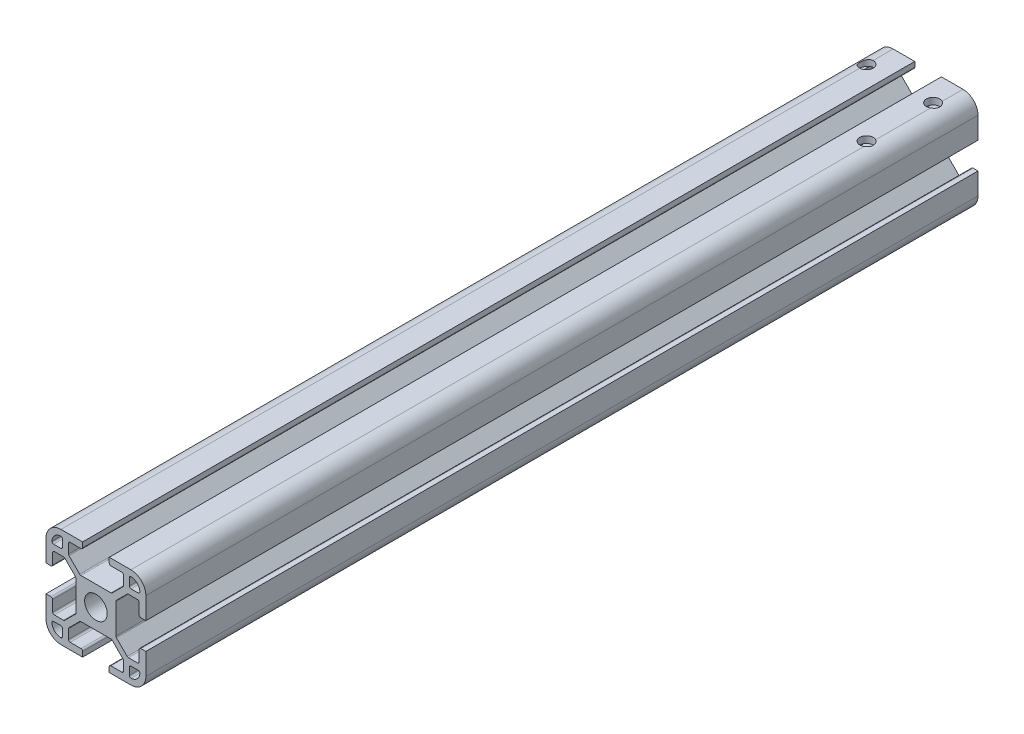
from build123d import *

# Parameters (mm, degrees)
SKETCH_1_R          = 3.4
EXTRUDE_1_DEPTH     = 250
CUT_EXTRUDE_1_REACH = 252
FILLET_1_R          = 0.5
SKETCH_15_R         = 2
CUT_EXTRUDE_2_DEPTH = 2


with BuildPart() as part:
    # 草圖1 → 填料-伸長1 (new body)
    with BuildSketch(Plane.XY):
        with BuildLine():
            Line((-10.5, 15), (10.5, 15))
            ThreePointArc((10.5, 15), (13.681980515, 13.681980515), (15, 10.5))
            Line((15, 10.5), (15, -10.5))
            ThreePointArc((15, -10.5), (13.681980515, -13.681980515), (10.5, -15))
            Line((10.5, -15), (-10.5, -15))
            ThreePointArc((-10.5, -15), (-13.681980515, -13.681980515), (-15, -10.5))
            Line((-15, -10.5), (-15, 10.5))
            ThreePointArc((-15, 10.5), (-13.681980515, 13.681980515), (-10.5, 15))
        make_face()
        Circle(SKETCH_1_R, mode=Mode.SUBTRACT)
    extrude(amount=-EXTRUDE_1_DEPTH)

    # 草圖2 → 除料-伸長1 (cut, up to next)
    with BuildSketch(Plane.XY, mode=Mode.PRIVATE) as cut_extrude_1_sk1:
        Polygon((-8.25, 13), (-8.25, 9.522792206), (-4.727207794, 6), (4.727207794, 6), (8.25, 9.522792206), (8.25, 13), (4, 13), (4, 15), (-4, 15), (-4, 13), align=None)
    cut_extrude_1_tool1 = extrude(cut_extrude_1_sk1.sketch, amount=-CUT_EXTRUDE_1_REACH, mode=Mode.PRIVATE) & part.part
    add(cut_extrude_1_tool1.solids().sort_by_distance((0, 10.346944, 0))[0], mode=Mode.SUBTRACT)
    # 草圖2 → 除料-伸長1 (cut, up to next)
    with BuildSketch(Plane.XY, mode=Mode.PRIVATE) as cut_extrude_1_sk2:
        Polygon((-9.522792206, 8.25), (-13, 8.25), (-13, 4), (-15, 4), (-15, -4), (-13, -4), (-13, -8.25), (-9.522792206, -8.25), (-6, -4.727207794), (-6, 4.727207794), align=None)
    cut_extrude_1_tool2 = extrude(cut_extrude_1_sk2.sketch, amount=-CUT_EXTRUDE_1_REACH, mode=Mode.PRIVATE) & part.part
    add(cut_extrude_1_tool2.solids().sort_by_distance((-10.346944, 0, 0))[0], mode=Mode.SUBTRACT)
    # 草圖2 → 除料-伸長1 (cut, up to next)
    with BuildSketch(Plane.XY, mode=Mode.PRIVATE) as cut_extrude_1_sk3:
        Polygon((15, 4), (13, 4), (13, 8.25), (9.522792206, 8.25), (6, 4.727207794), (6, -4.727207794), (9.522792206, -8.25), (13, -8.25), (13, -4), (15, -4), align=None)
    cut_extrude_1_tool3 = extrude(cut_extrude_1_sk3.sketch, amount=-CUT_EXTRUDE_1_REACH, mode=Mode.PRIVATE) & part.part
    add(cut_extrude_1_tool3.solids().sort_by_distance((10.346944, 0, 0))[0], mode=Mode.SUBTRACT)
    # 草圖2 → 除料-伸長1 (cut, up to next)
    with BuildSketch(Plane.XY, mode=Mode.PRIVATE) as cut_extrude_1_sk4:
        with BuildLine():
            Line((-10.05, 13.2), (-10.05, 10.05))
            Line((-10.05, 10.05), (-13.2, 10.05))
            Line((-13.2, 10.05), (-13.2, 10.5))
            ThreePointArc((-13.2, 10.5), (-12.409188309, 12.409188309), (-10.5, 13.2))
            Line((-10.5, 13.2), (-10.05, 13.2))
        make_face()
    cut_extrude_1_tool4 = extrude(cut_extrude_1_sk4.sketch, amount=-CUT_EXTRUDE_1_REACH, mode=Mode.PRIVATE) & part.part
    add(cut_extrude_1_tool4.solids().sort_by_distance((-11.44308, 11.44308, 0))[0], mode=Mode.SUBTRACT)
    # 草圖2 → 除料-伸長1 (cut, up to next)
    with BuildSketch(Plane.XY, mode=Mode.PRIVATE) as cut_extrude_1_sk5:
        with BuildLine():
            Line((10.05, 13.2), (10.05, 10.05))
            Line((10.05, 10.05), (13.2, 10.05))
            Line((13.2, 10.05), (13.2, 10.5))
            ThreePointArc((13.2, 10.5), (12.409188309, 12.409188309), (10.5, 13.2))
            Line((10.5, 13.2), (10.05, 13.2))
        make_face()
    cut_extrude_1_tool5 = extrude(cut_extrude_1_sk5.sketch, amount=-CUT_EXTRUDE_1_REACH, mode=Mode.PRIVATE) & part.part
    add(cut_extrude_1_tool5.solids().sort_by_distance((11.44308, 11.44308, 0))[0], mode=Mode.SUBTRACT)
    # 草圖2 → 除料-伸長1 (cut, up to next)
    with BuildSketch(Plane.XY, mode=Mode.PRIVATE) as cut_extrude_1_sk6:
        with BuildLine():
            Line((10.05, -10.05), (13.2, -10.05))
            Line((13.2, -10.05), (13.2, -10.5))
            ThreePointArc((13.2, -10.5), (12.409188309, -12.409188309), (10.5, -13.2))
            Line((10.5, -13.2), (10.05, -13.2))
            Line((10.05, -13.2), (10.05, -10.05))
        make_face()
    cut_extrude_1_tool6 = extrude(cut_extrude_1_sk6.sketch, amount=-CUT_EXTRUDE_1_REACH, mode=Mode.PRIVATE) & part.part
    add(cut_extrude_1_tool6.solids().sort_by_distance((11.44308, -11.44308, 0))[0], mode=Mode.SUBTRACT)
    # 草圖2 → 除料-伸長1 (cut, up to next)
    with BuildSketch(Plane.XY, mode=Mode.PRIVATE) as cut_extrude_1_sk7:
        with BuildLine():
            Line((-10.05, -10.05), (-13.2, -10.05))
            Line((-13.2, -10.05), (-13.2, -10.5))
            ThreePointArc((-13.2, -10.5), (-12.409188309, -12.409188309), (-10.5, -13.2))
            Line((-10.5, -13.2), (-10.05, -13.2))
            Line((-10.05, -13.2), (-10.05, -10.05))
        make_face()
    cut_extrude_1_tool7 = extrude(cut_extrude_1_sk7.sketch, amount=-CUT_EXTRUDE_1_REACH, mode=Mode.PRIVATE) & part.part
    add(cut_extrude_1_tool7.solids().sort_by_distance((-11.44308, -11.44308, 0))[0], mode=Mode.SUBTRACT)
    # 草圖2 → 除料-伸長1 (cut, up to next)
    with BuildSketch(Plane.XY, mode=Mode.PRIVATE) as cut_extrude_1_sk8:
        Polygon((-4, -15), (-4, -13), (-8.25, -13), (-8.25, -9.522792206), (-4.727207794, -6), (4.727207794, -6), (8.25, -9.522792206), (8.25, -13), (4, -13), (4, -15), align=None)
    cut_extrude_1_tool8 = extrude(cut_extrude_1_sk8.sketch, amount=-CUT_EXTRUDE_1_REACH, mode=Mode.PRIVATE) & part.part
    add(cut_extrude_1_tool8.solids().sort_by_distance((0, -10.346944, 0))[0], mode=Mode.SUBTRACT)

    # 圓角1
    fillet_1_edges = [part.edges().sort_by_distance(p)[0] for p in [
        (-4, -13, -125),
        (4, -13, -125),
        (4, 13, -125),
        (9.522792206, 8.25, -125),
        (13, 8.25, -125),
        (13, 4, -125),
        (13, -4, -125),
        (9.522792206, -8.25, -125),
        (13, -8.25, -125),
        (8.25, -13, -125),
        (-8.25, -13, -125),
        (8.25, -9.522792206, -125),
        (-8.25, -9.522792206, -125),
        (-4.727207794, -6, -125),
        (4.727207794, -6, -125),
        (6, -4.727207794, -125),
        (6, 4.727207794, -125),
        (4.727207794, 6, -125),
        (-6, 4.727207794, -125),
        (-6, -4.727207794, -125),
        (-9.522792206, -8.25, -125),
        (-13, -8.25, -125),
        (-13, -4, -125),
        (-13, 4, -125),
        (-9.522792206, 8.25, -125),
        (-13, 8.25, -125),
        (-4.727207794, 6, -125),
        (-8.25, 9.522792206, -125),
        (-4, 13, -125),
        (-8.25, 13, -125),
        (10.05, 13.2, -125),
        (10.05, 10.05, -125),
        (13.2, 10.05, -125),
        (-10.05, 13.2, -125),
        (-10.05, 10.05, -125),
        (-13.2, 10.05, -125),
        (-13.2, -10.05, -125),
        (-10.05, -13.2, -125),
        (10.05, -13.2, -125),
        (13.2, -10.05, -125),
        (10.05, -10.05, -125),
        (-10.05, -10.05, -125),
        (8.25, 9.522792206, -125),
        (8.25, 13, -125),
    ]]
    fillet(fillet_1_edges, radius=FILLET_1_R)

    # 草圖15 → 除料-伸長2 (cut)
    with BuildSketch(Plane(origin=(0, 15, 0), x_dir=(1, 0, 0), z_dir=(0, 1, 0))):
        with Locations((9.5, 242)):
            Circle(SKETCH_15_R)
        with Locations((9.5, 222)):
            Circle(SKETCH_15_R)
        with Locations((-10.5, 242)):
            Circle(SKETCH_15_R)
    extrude(amount=-CUT_EXTRUDE_2_DEPTH, mode=Mode.SUBTRACT)


solid = part.part
